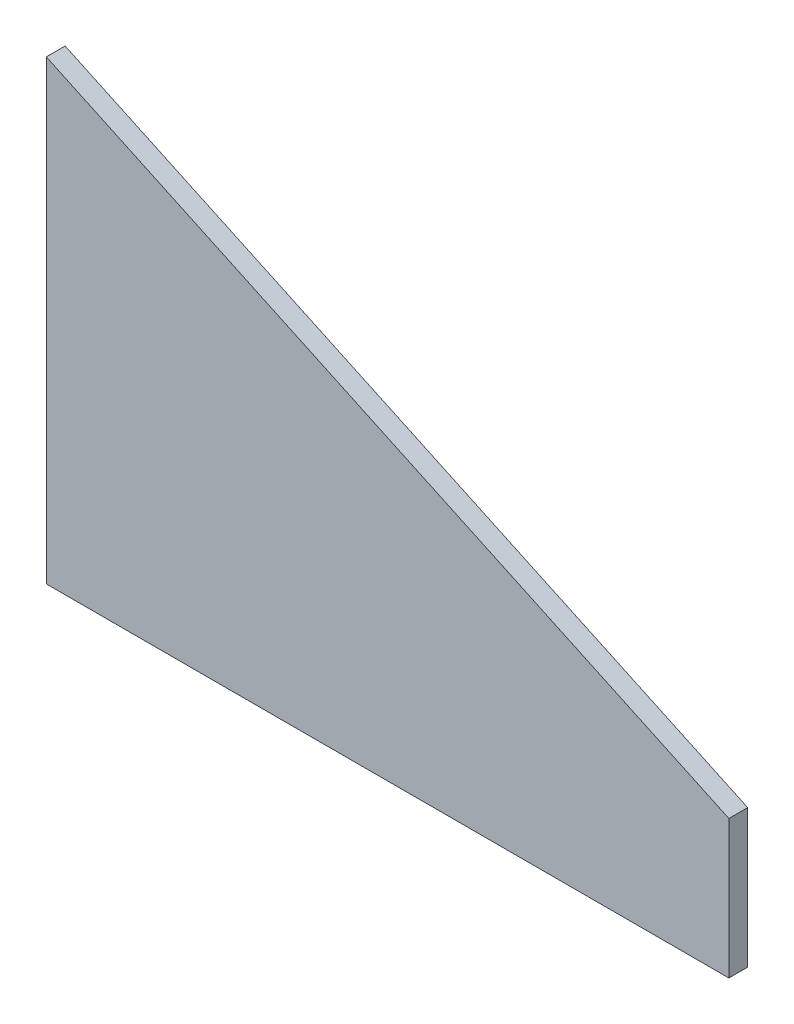
from build123d import *

# Parameters (mm, degrees)
BOSS_EXTRUDE1_DEPTH = 6.35


with BuildPart() as part:
    # Sketch1 → Boss-Extrude1 (new body)
    with BuildSketch(Plane.XY):
        Polygon((0, 0), (230.202177907, 0), (230.202177907, 46.590065352), (0, 153.935103834), align=None)
    extrude(amount=BOSS_EXTRUDE1_DEPTH)


solid = part.part
